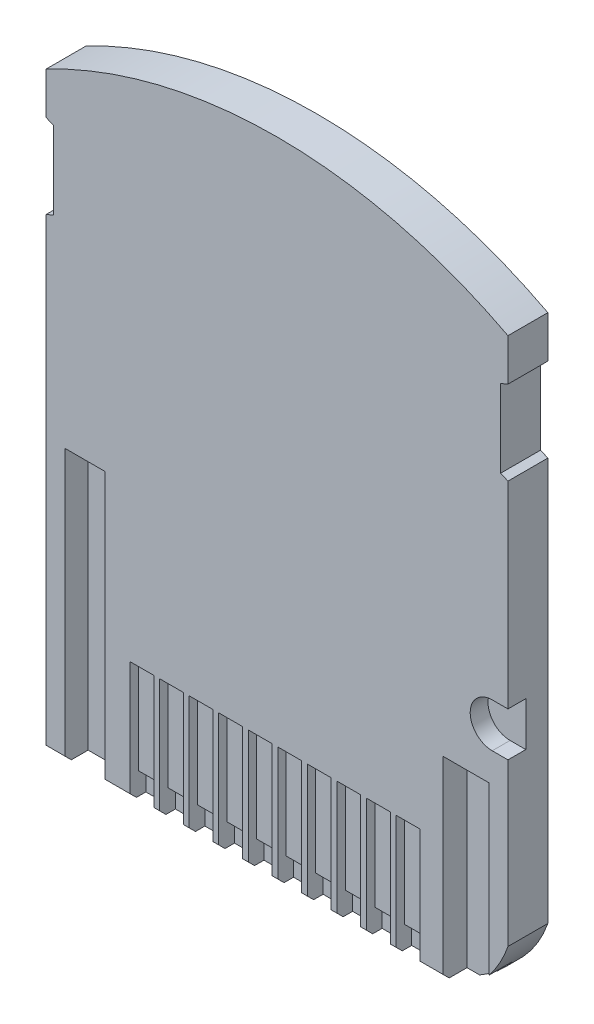
from build123d import *

# Parameters (mm, degrees)
SKETCH1_W           = 22
SKETCH1_H           = 1.9
BOSS_EXTRUDE1_DEPTH = 31.1
CUT_EXTRUDE2_REACH  = 35.043
CUT_EXTRUDE3_REACH  = 34.855
CUT_EXTRUDE4_DEPTH  = 0.85
CHAMFER1_SIZE       = 0.3
SKETCH2_8_W         = 1.9
SKETCH2_8_H         = 13
CUT_EXTRUDE6_DEPTH  = 1.1
CUT_EXTRUDE7_DEPTH  = 1.15
SKETCH2_10_W        = 1.137
SKETCH2_10_H        = 1.05
CUT_EXTRUDE8_DEPTH  = 0.75
SKETCH2_11_W        = 1.137
SKETCH2_11_H        = 4.7
CUT_EXTRUDE9_DEPTH  = 0.4
CUT_EXTRUDE10_DEPTH = 0.2
CUT_EXTRUDE12_DEPTH = 0.1


with BuildPart() as part:
    # Sketch1 → Boss-Extrude1 (new body)
    with BuildSketch(Plane(origin=(0, 0, 0), x_dir=(1, 0, 0), z_dir=(0, 1, 0))):
        Rectangle(SKETCH1_W, SKETCH1_H)
    extrude(amount=BOSS_EXTRUDE1_DEPTH)

    # Sketch2 → Cut-Extrude2 (cut, up to next)
    with BuildSketch(Plane.XY.offset(0.95), mode=Mode.PRIVATE) as cut_extrude2_sk1:
        with BuildLine():
            Line((-11, 31.1), (-11, 28.2))
            ThreePointArc((-11, 28.2), (0, 30.9), (11, 28.2))
            Line((11, 28.2), (11, 31.1))
            Line((11, 31.1), (-11, 31.1))
        make_face()
    cut_extrude2_tool1 = extrude(cut_extrude2_sk1.sketch, amount=-CUT_EXTRUDE2_REACH, mode=Mode.PRIVATE) & part.part
    add(cut_extrude2_tool1.solids().sort_by_distance((10.778097, 29.65, 0.95))[0], mode=Mode.SUBTRACT)

    # Sketch2_4 → Cut-Extrude3 (cut, up to next)
    with BuildSketch(Plane.XY.offset(0.95), mode=Mode.PRIVATE) as cut_extrude3_sk1:
        Polygon((-11, 26.2), (-11, 22.2), (-10.65, 22.35), (-10.65, 26.05), align=None)
    cut_extrude3_tool1 = extrude(cut_extrude3_sk1.sketch, amount=-CUT_EXTRUDE3_REACH, mode=Mode.PRIVATE) & part.part
    # Sketch2_4 → Cut-Extrude3 (cut, up to next)
    with BuildSketch(Plane.XY.offset(0.95), mode=Mode.PRIVATE) as cut_extrude3_sk2:
        Polygon((11, 22.2), (11, 26.2), (10.65, 26.05), (10.65, 22.35), align=None)
    cut_extrude3_tool2 = extrude(cut_extrude3_sk2.sketch, amount=-CUT_EXTRUDE3_REACH, mode=Mode.PRIVATE) & part.part
    # Sketch2_4 → Cut-Extrude3 (cut, up to next)
    with BuildSketch(Plane.XY.offset(0.95), mode=Mode.PRIVATE) as cut_extrude3_sk3:
        with BuildLine():
            Line((11, 0), (11, 3))
            ThreePointArc((11, 3), (10.022572528, 1.272856226), (8.5, 0))
            Line((8.5, 0), (11, 0))
        make_face()
    cut_extrude3_tool3 = extrude(cut_extrude3_sk3.sketch, amount=-CUT_EXTRUDE3_REACH, mode=Mode.PRIVATE) & part.part
    add(cut_extrude3_tool1.solids().sort_by_distance((-10.827273, 24.2, 0.95))[0], mode=Mode.SUBTRACT)
    add(cut_extrude3_tool2.solids().sort_by_distance((10.827273, 24.2, 0.95))[0], mode=Mode.SUBTRACT)
    add(cut_extrude3_tool3.solids().sort_by_distance((10.267991, 0.865194, 0.95))[0], mode=Mode.SUBTRACT)

    # Sketch2_5 → Cut-Extrude4 (cut)
    with BuildSketch(Plane.XY.offset(0.95)):
        with BuildLine():
            Line((11, 10.7), (11, 12.8))
            Line((11, 12.8), (10.25, 12.8))
            ThreePointArc((10.25, 12.8), (9.2, 11.75), (10.25, 10.7))
            Line((10.25, 10.7), (11, 10.7))
        make_face()
    extrude(amount=-CUT_EXTRUDE4_DEPTH, mode=Mode.SUBTRACT)

    # Chamfer1
    chamfer1_edges = [part.edges().sort_by_distance(p)[0] for p in [
        (-1.25, 0, 0.95),
    ]]
    chamfer(chamfer1_edges, length=CHAMFER1_SIZE)

    # Sketch2_8 → Cut-Extrude6 (cut)
    with BuildSketch(Plane.XY.offset(0.95)):
        with Locations((-9.15, 6.5)):
            Rectangle(SKETCH2_8_W, SKETCH2_8_H)
    extrude(amount=-CUT_EXTRUDE6_DEPTH, mode=Mode.SUBTRACT)

    # Sketch2_9 → Cut-Extrude7 (cut)
    with BuildSketch(Plane.XY.offset(0.95)):
        with BuildLine():
            ThreePointArc((8.5, 0), (9.365445636, 0.607390694), (10.1, 1.36788362))
            Line((10.1, 1.36788362), (10.1, 9.3))
            Line((10.1, 9.3), (7.9, 9.3))
            Line((7.9, 9.3), (7.9, 0))
            Line((7.9, 0), (8.5, 0))
        make_face()
    extrude(amount=-CUT_EXTRUDE7_DEPTH, mode=Mode.SUBTRACT)

    # Sketch2_10 → Cut-Extrude8 (cut)
    with BuildSketch(Plane.XY.offset(0.95)):
        with Locations((-6.4315, 0.525)):
            Rectangle(SKETCH2_10_W, SKETCH2_10_H)
        with Locations((-5.0245, 0.525)):
            Rectangle(SKETCH2_10_W, SKETCH2_10_H)
        with Locations((-3.6175, 0.525)):
            Rectangle(SKETCH2_10_W, SKETCH2_10_H)
        with Locations((-2.2105, 0.525)):
            Rectangle(SKETCH2_10_W, SKETCH2_10_H)
        with Locations((-0.8035, 0.525)):
            Rectangle(SKETCH2_10_W, SKETCH2_10_H)
        with Locations((0.6035, 0.525)):
            Rectangle(SKETCH2_10_W, SKETCH2_10_H)
        with Locations((2.0105, 0.525)):
            Rectangle(SKETCH2_10_W, SKETCH2_10_H)
        with Locations((3.4175, 0.525)):
            Rectangle(SKETCH2_10_W, SKETCH2_10_H)
        with Locations((6.2315, 0.525)):
            Rectangle(SKETCH2_10_W, SKETCH2_10_H)
        with Locations((4.8245, 0.525)):
            Rectangle(SKETCH2_10_W, SKETCH2_10_H)
    extrude(amount=-CUT_EXTRUDE8_DEPTH, mode=Mode.SUBTRACT)

    # Sketch2_11 → Cut-Extrude9 (cut)
    with BuildSketch(Plane.XY.offset(0.95)):
        with Locations((-6.4315, 3.4)):
            Rectangle(SKETCH2_11_W, SKETCH2_11_H)
        with Locations((-5.0245, 3.4)):
            Rectangle(SKETCH2_11_W, SKETCH2_11_H)
        with Locations((-3.6175, 3.4)):
            Rectangle(SKETCH2_11_W, SKETCH2_11_H)
        with Locations((-2.2105, 3.4)):
            Rectangle(SKETCH2_11_W, SKETCH2_11_H)
        with Locations((-0.8035, 3.4)):
            Rectangle(SKETCH2_11_W, SKETCH2_11_H)
        with Locations((0.6035, 3.4)):
            Rectangle(SKETCH2_11_W, SKETCH2_11_H)
        with Locations((2.0105, 3.4)):
            Rectangle(SKETCH2_11_W, SKETCH2_11_H)
        with Locations((3.4175, 3.4)):
            Rectangle(SKETCH2_11_W, SKETCH2_11_H)
        with Locations((6.2315, 3.4)):
            Rectangle(SKETCH2_11_W, SKETCH2_11_H)
        with Locations((4.8245, 3.4)):
            Rectangle(SKETCH2_11_W, SKETCH2_11_H)
    extrude(amount=-CUT_EXTRUDE9_DEPTH, mode=Mode.SUBTRACT)

    # Sketch5 → Cut-Extrude10 (cut)
    with BuildSketch(Plane(origin=(0, 0, -0.95), x_dir=(-1, 0, 0), z_dir=(0, 0, -1))):
        with BuildLine():
            Line((-9.4, 4.6), (-9.4, 27.207255635))
            ThreePointArc((-9.4, 27.207255635), (0, 29.3), (9.4, 27.207255635))
            Line((9.4, 27.207255635), (9.4, 4.6))
            Line((9.4, 4.6), (-9.4, 4.6))
        make_face()
    extrude(amount=-CUT_EXTRUDE10_DEPTH, mode=Mode.SUBTRACT)

    # Sketch6 → Cut-Extrude12 (cut)
    with BuildSketch(Plane(origin=(0, 0, -0.95), x_dir=(-1, 0, 0), z_dir=(0, 0, -1))):
        Polygon((-3.15, 3.48074093), (3.15, 3.48074093), (0, 1.58074093), align=None)
    extrude(amount=-CUT_EXTRUDE12_DEPTH, mode=Mode.SUBTRACT)


solid = part.part
